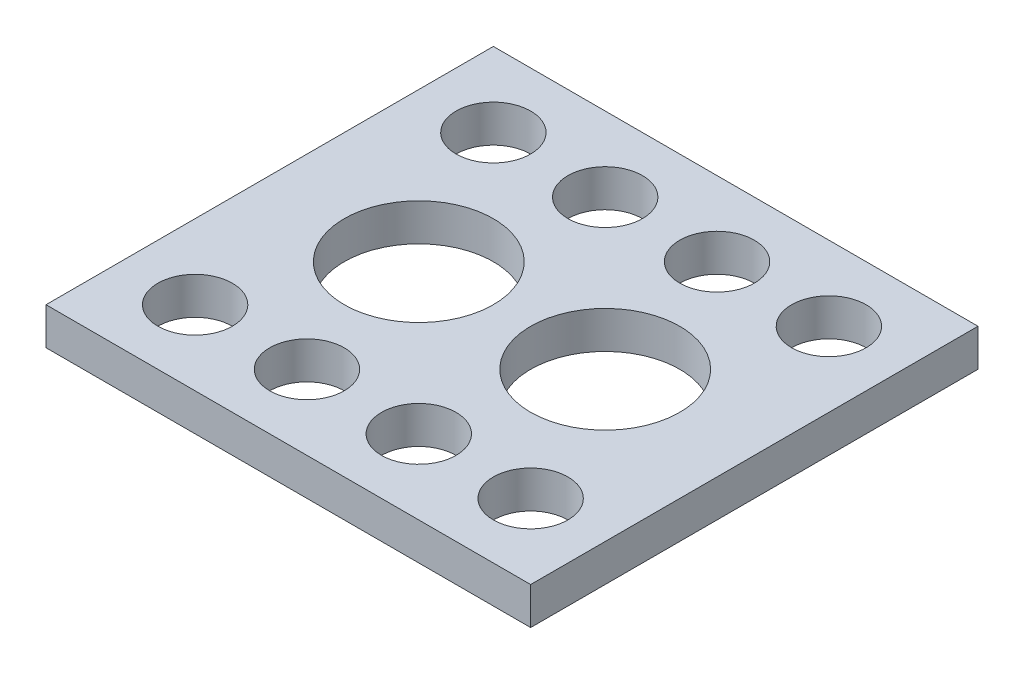
from build123d import *

# Parameters (mm, degrees)
SKETCH1_W           = 165.1
SKETCH1_H           = 152.4
BOSS_EXTRUDE1_DEPTH = 12.7
SKETCH2_R           = 12.7
CUT_EXTRUDE1_DEPTH  = 12.7
SKETCH3_R           = 25.4
CUT_EXTRUDE2_DEPTH  = 12.7


with BuildPart() as part:
    # Sketch1 → Boss-Extrude1 (new body)
    with BuildSketch(Plane(origin=(0, 0, 0), x_dir=(1, 0, 0), z_dir=(0, 1, 0))):
        with Locations((82.55, 76.2)):
            Rectangle(SKETCH1_W, SKETCH1_H)
    extrude(amount=-BOSS_EXTRUDE1_DEPTH)

    # Sketch2 → Cut-Extrude1 (cut)
    with BuildSketch(Plane(origin=(0, 0, 0), x_dir=(1, 0, 0), z_dir=(0, 1, 0))):
        with Locations((25.4, 127)):
            Circle(SKETCH2_R)
        with Locations((63.5, 127)):
            Circle(SKETCH2_R)
        with Locations((101.6, 127)):
            Circle(SKETCH2_R)
        with Locations((139.7, 127)):
            Circle(SKETCH2_R)
        with Locations((63.5, 25.4)):
            Circle(SKETCH2_R)
        with Locations((101.6, 25.4)):
            Circle(SKETCH2_R)
        with Locations((139.7, 25.4)):
            Circle(SKETCH2_R)
        with Locations((25.4, 25.4)):
            Circle(SKETCH2_R)
    extrude(amount=-CUT_EXTRUDE1_DEPTH, mode=Mode.SUBTRACT)

    # Sketch3 → Cut-Extrude2 (cut)
    with BuildSketch(Plane(origin=(0, 0, 0), x_dir=(1, 0, 0), z_dir=(0, 1, 0))):
        with Locations((50.8, 76.2)):
            Circle(SKETCH3_R)
        with Locations((114.3, 76.2)):
            Circle(SKETCH3_R)
    extrude(amount=-CUT_EXTRUDE2_DEPTH, mode=Mode.SUBTRACT)


solid = part.part
